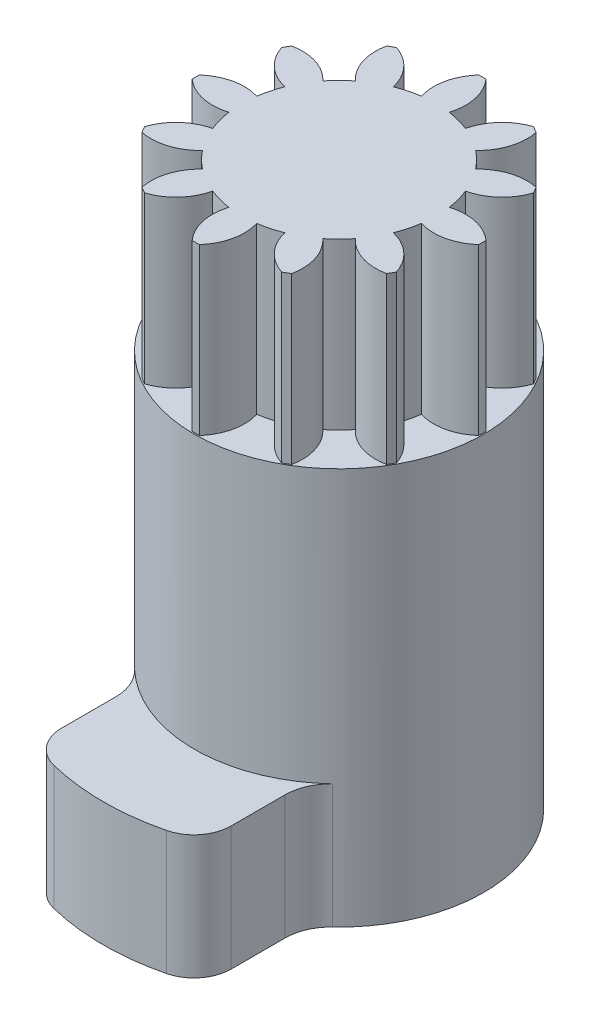
from build123d import *

# Parameters (mm, degrees)
SKETCH1_R           = 17.5
BOSS_EXTRUDE1_DEPTH = 48
BOSS_EXTRUDE2_DEPTH = 15
BOSS_EXTRUDE3_DEPTH = 20


with BuildPart() as part:
    # Sketch1 → Boss-Extrude1 (new body)
    with BuildSketch(Plane(origin=(0, 0, 0), x_dir=(1, 0, 0), z_dir=(0, 1, 0))):
        Circle(SKETCH1_R)
    extrude(amount=BOSS_EXTRUDE1_DEPTH)

    # Sketch4 → Boss-Extrude2 (add)
    with BuildSketch(Plane.XZ):
        with BuildLine():
            Line((10.25, 23.304288773), (10.25, 16.761190292))
            ThreePointArc((10.25, 16.761190292), (10.701996736, 14.5776924), (11.983695652, 12.75307957))
            ThreePointArc((11.983695652, 12.75307957), (0, 17.5), (-11.983695652, 12.75307957))
            ThreePointArc((-11.983695652, 12.75307957), (-10.701996736, 14.5776924), (-10.25, 16.761190292))
            Line((-10.25, 16.761190292), (-10.25, 23.304288773))
            ThreePointArc((-10.25, 23.304288773), (-9.292662905, 26.079093189), (-6.827982425, 27.673265071))
            ThreePointArc((-6.827982425, 27.673265071), (0, 28.503174274), (6.827982425, 27.673265071))
            ThreePointArc((6.827982425, 27.673265071), (9.292662905, 26.079093189), (10.25, 23.304288773))
        make_face()
    extrude(amount=-BOSS_EXTRUDE2_DEPTH)

    # Sketch6 → Boss-Extrude3 (add)
    with BuildSketch(Plane(origin=(0, 48, 0), x_dir=(1, 0, 0), z_dir=(0, 1, 0))):
        with BuildLine():
            ThreePointArc((11.641553947, -1.685099566), (14.648632583, -1.806960077), (17.329910897, -0.440168758))
            ThreePointArc((17.329910897, -0.440168758), (17.3355, 0), (17.329910897, 0.440168758))
            ThreePointArc((17.329910897, 0.440168758), (14.648632583, 1.806960077), (11.641553947, 1.685099566))
            ThreePointArc((11.641553947, 1.685099566), (11.362069294, 3.044457292), (10.92443124, 4.361437941))
            ThreePointArc((10.92443124, 4.361437941), (13.589567986, 5.759442961), (15.228227462, 8.283758122))
            ThreePointArc((15.228227462, 8.283758122), (15.012983387, 8.66775), (14.788058703, 9.046152775))
            ThreePointArc((14.788058703, 9.046152775), (11.782607909, 8.889189622), (9.239331674, 7.280116005))
            ThreePointArc((9.239331674, 7.280116005), (8.317612002, 8.317612002), (7.280116005, 9.239331674))
            ThreePointArc((7.280116005, 9.239331674), (8.889189622, 11.782607909), (9.046152775, 14.788058703))
            ThreePointArc((9.046152775, 14.788058703), (8.66775, 15.012983387), (8.283758122, 15.228227462))
            ThreePointArc((8.283758122, 15.228227462), (5.759442961, 13.589567986), (4.361437941, 10.92443124))
            ThreePointArc((4.361437941, 10.92443124), (3.044457292, 11.362069294), (1.685099566, 11.641553947))
            ThreePointArc((1.685099566, 11.641553947), (1.806960077, 14.648632583), (0.440168758, 17.329910897))
            ThreePointArc((0.440168758, 17.329910897), (0, 17.3355), (-0.440168758, 17.329910897))
            ThreePointArc((-0.440168758, 17.329910897), (-1.806960077, 14.648632583), (-1.685099566, 11.641553947))
            ThreePointArc((-1.685099566, 11.641553947), (-3.044457292, 11.362069294), (-4.361437941, 10.92443124))
            ThreePointArc((-4.361437941, 10.92443124), (-5.759442961, 13.589567986), (-8.283758122, 15.228227462))
            ThreePointArc((-8.283758122, 15.228227462), (-8.66775, 15.012983387), (-9.046152775, 14.788058703))
            ThreePointArc((-9.046152775, 14.788058703), (-8.889189622, 11.782607909), (-7.280116005, 9.239331674))
            ThreePointArc((-7.280116005, 9.239331674), (-8.317612002, 8.317612002), (-9.239331674, 7.280116005))
            ThreePointArc((-9.239331674, 7.280116005), (-11.782607909, 8.889189622), (-14.788058703, 9.046152775))
            ThreePointArc((-14.788058703, 9.046152775), (-15.012983387, 8.66775), (-15.228227462, 8.283758122))
            ThreePointArc((-15.228227462, 8.283758122), (-13.589567986, 5.759442961), (-10.92443124, 4.361437941))
            ThreePointArc((-10.92443124, 4.361437941), (-11.362069294, 3.044457292), (-11.641553947, 1.685099566))
            ThreePointArc((-11.641553947, 1.685099566), (-14.648632583, 1.806960077), (-17.329910897, 0.440168758))
            ThreePointArc((-17.329910897, 0.440168758), (-17.3355, 0), (-17.329910897, -0.440168758))
            ThreePointArc((-17.329910897, -0.440168758), (-14.648632583, -1.806960077), (-11.641553947, -1.685099566))
            ThreePointArc((-11.641553947, -1.685099566), (-11.362069294, -3.044457292), (-10.92443124, -4.361437941))
            ThreePointArc((-10.92443124, -4.361437941), (-13.589567986, -5.759442961), (-15.228227462, -8.283758122))
            ThreePointArc((-15.228227462, -8.283758122), (-15.012983387, -8.66775), (-14.788058703, -9.046152775))
            ThreePointArc((-14.788058703, -9.046152775), (-11.782607909, -8.889189622), (-9.239331674, -7.280116005))
            ThreePointArc((-9.239331674, -7.280116005), (-8.317612002, -8.317612002), (-7.280116005, -9.239331674))
            ThreePointArc((-7.280116005, -9.239331674), (-8.889189622, -11.782607909), (-9.046152775, -14.788058703))
            ThreePointArc((-9.046152775, -14.788058703), (-8.66775, -15.012983387), (-8.283758122, -15.228227462))
            ThreePointArc((-8.283758122, -15.228227462), (-5.759442961, -13.589567986), (-4.361437941, -10.92443124))
            ThreePointArc((-4.361437941, -10.92443124), (-3.044457292, -11.362069294), (-1.685099566, -11.641553947))
            ThreePointArc((-1.685099566, -11.641553947), (-1.806960077, -14.648632583), (-0.440168758, -17.329910897))
            ThreePointArc((-0.440168758, -17.329910897), (0, -17.3355), (0.440168758, -17.329910897))
            ThreePointArc((0.440168758, -17.329910897), (1.806960077, -14.648632583), (1.685099566, -11.641553947))
            ThreePointArc((1.685099566, -11.641553947), (3.044457292, -11.362069294), (4.361437941, -10.92443124))
            ThreePointArc((4.361437941, -10.92443124), (5.759442961, -13.589567986), (8.283758122, -15.228227462))
            ThreePointArc((8.283758122, -15.228227462), (8.66775, -15.012983387), (9.046152775, -14.788058703))
            ThreePointArc((9.046152775, -14.788058703), (8.889189622, -11.782607909), (7.280116005, -9.239331674))
            ThreePointArc((7.280116005, -9.239331674), (8.317612002, -8.317612002), (9.239331674, -7.280116005))
            ThreePointArc((9.239331674, -7.280116005), (11.782607909, -8.889189622), (14.788058703, -9.046152775))
            ThreePointArc((14.788058703, -9.046152775), (15.012983387, -8.66775), (15.228227462, -8.283758122))
            ThreePointArc((15.228227462, -8.283758122), (13.589567986, -5.759442961), (10.92443124, -4.361437941))
            ThreePointArc((10.92443124, -4.361437941), (11.362069294, -3.044457292), (11.641553947, -1.685099566))
        make_face()
    extrude(amount=BOSS_EXTRUDE3_DEPTH)


solid = part.part
